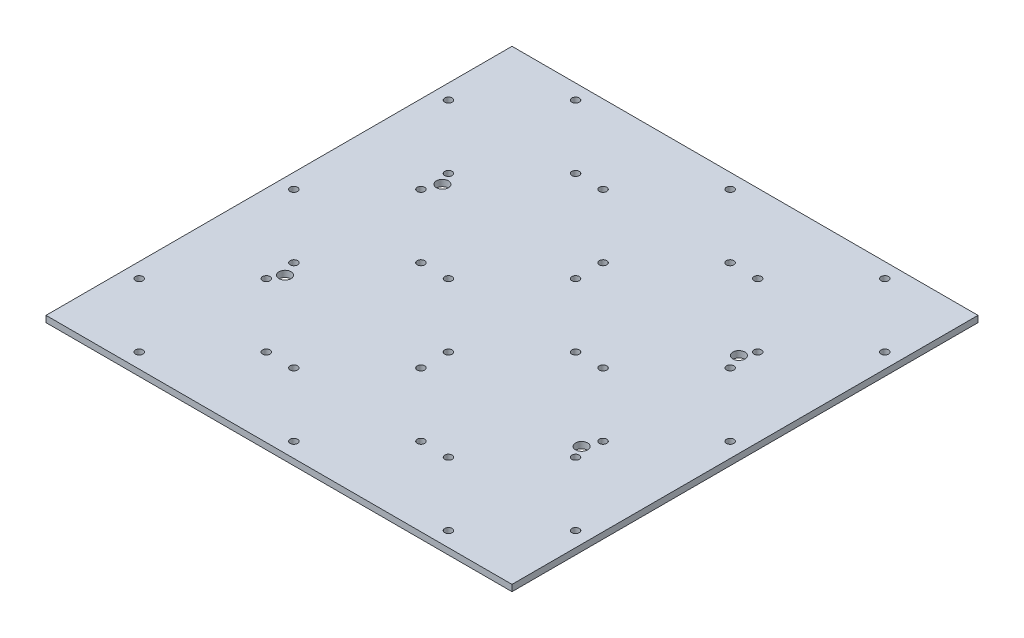
from build123d import *

# Parameters (mm, degrees)
SKETCH1_W           = 220
SKETCH1_H           = 220
BOSS_EXTRUDE1_DEPTH = 3
SKETCH3_R           = 2.85
CUT_EXTRUDE5_DEPTH  = 4
SKETCH2_R           = 1.7526
CUT_EXTRUDE6_DEPTH  = 4


with BuildPart() as part:
    # Sketch1 → Boss-Extrude1 (new body)
    with BuildSketch(Plane(origin=(0, 0, 0), x_dir=(1, 0, 0), z_dir=(0, 1, 0))):
        Rectangle(SKETCH1_W, SKETCH1_H)
    extrude(amount=BOSS_EXTRUDE1_DEPTH)

    # Sketch3 → Cut-Extrude5 (cut, through all)
    with BuildSketch(Plane(origin=(0, 3, 0), x_dir=(1, 0, 0), z_dir=(0, 1, 0))):
        with Locations((70, -37.15)):
            Circle(SKETCH3_R)
        with Locations((-70, -37.15)):
            Circle(SKETCH3_R)
        with Locations((-70, 37.15)):
            Circle(SKETCH3_R)
        with Locations((70, 37.15)):
            Circle(SKETCH3_R)
    extrude(amount=-CUT_EXTRUDE5_DEPTH, mode=Mode.SUBTRACT)

    # Sketch2 → Cut-Extrude6 (cut, through all)
    with BuildSketch(Plane(origin=(0, 3, 0), x_dir=(1, 0, 0), z_dir=(0, 1, 0))):
        with Locations((-73, 103)):
            Circle(SKETCH2_R)
        with Locations((0, 103)):
            Circle(SKETCH2_R)
        with Locations((-30, 73)):
            Circle(SKETCH2_R)
        with Locations((-103, 73)):
            Circle(SKETCH2_R)
        with Locations((-43, 73)):
            Circle(SKETCH2_R)
        with Locations((0, 43)):
            Circle(SKETCH2_R)
        with Locations((30, 73)):
            Circle(SKETCH2_R)
        with Locations((73, 103)):
            Circle(SKETCH2_R)
        with Locations((43, 73)):
            Circle(SKETCH2_R)
        with Locations((-73, 43)):
            Circle(SKETCH2_R)
        with Locations((73, 43)):
            Circle(SKETCH2_R)
        with Locations((103, 73)):
            Circle(SKETCH2_R)
        with Locations((0, 30)):
            Circle(SKETCH2_R)
        with Locations((-30, 0)):
            Circle(SKETCH2_R)
        with Locations((0, -30)):
            Circle(SKETCH2_R)
        with Locations((30, 0)):
            Circle(SKETCH2_R)
        with Locations((73, 30)):
            Circle(SKETCH2_R)
        with Locations((43, 0)):
            Circle(SKETCH2_R)
        with Locations((73, -30)):
            Circle(SKETCH2_R)
        with Locations((103, 0)):
            Circle(SKETCH2_R)
        with Locations((0, -43)):
            Circle(SKETCH2_R)
        with Locations((-30, -73)):
            Circle(SKETCH2_R)
        with Locations((0, -103)):
            Circle(SKETCH2_R)
        with Locations((30, -73)):
            Circle(SKETCH2_R)
        with Locations((73, -43)):
            Circle(SKETCH2_R)
        with Locations((43, -73)):
            Circle(SKETCH2_R)
        with Locations((73, -103)):
            Circle(SKETCH2_R)
        with Locations((103, -73)):
            Circle(SKETCH2_R)
        with Locations((-73, 30)):
            Circle(SKETCH2_R)
        with Locations((-103, 0)):
            Circle(SKETCH2_R)
        with Locations((-73, -30)):
            Circle(SKETCH2_R)
        with Locations((-43, 0)):
            Circle(SKETCH2_R)
        with Locations((-73, -43)):
            Circle(SKETCH2_R)
        with Locations((-103, -73)):
            Circle(SKETCH2_R)
        with Locations((-73, -103)):
            Circle(SKETCH2_R)
        with Locations((-43, -73)):
            Circle(SKETCH2_R)
    extrude(amount=-CUT_EXTRUDE6_DEPTH, mode=Mode.SUBTRACT)


solid = part.part
